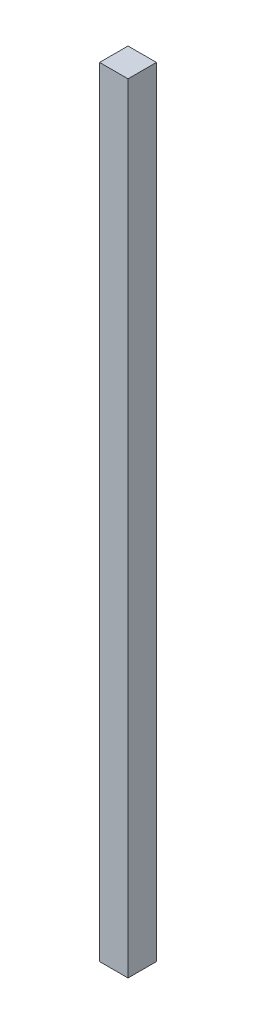
from build123d import *

# Parameters (mm, degrees)
ESQUISSE1_W        = 10
ESQUISSE1_H        = 274
BOSS_EXTRU_1_DEPTH = 10


with BuildPart() as part:
    # Esquisse1 → Boss.-Extru.1 (new body)
    with BuildSketch(Plane.XY):
        with Locations((-46.423914476, -99.8040658)):
            Rectangle(ESQUISSE1_W, ESQUISSE1_H)
    extrude(amount=BOSS_EXTRU_1_DEPTH)


solid = part.part
